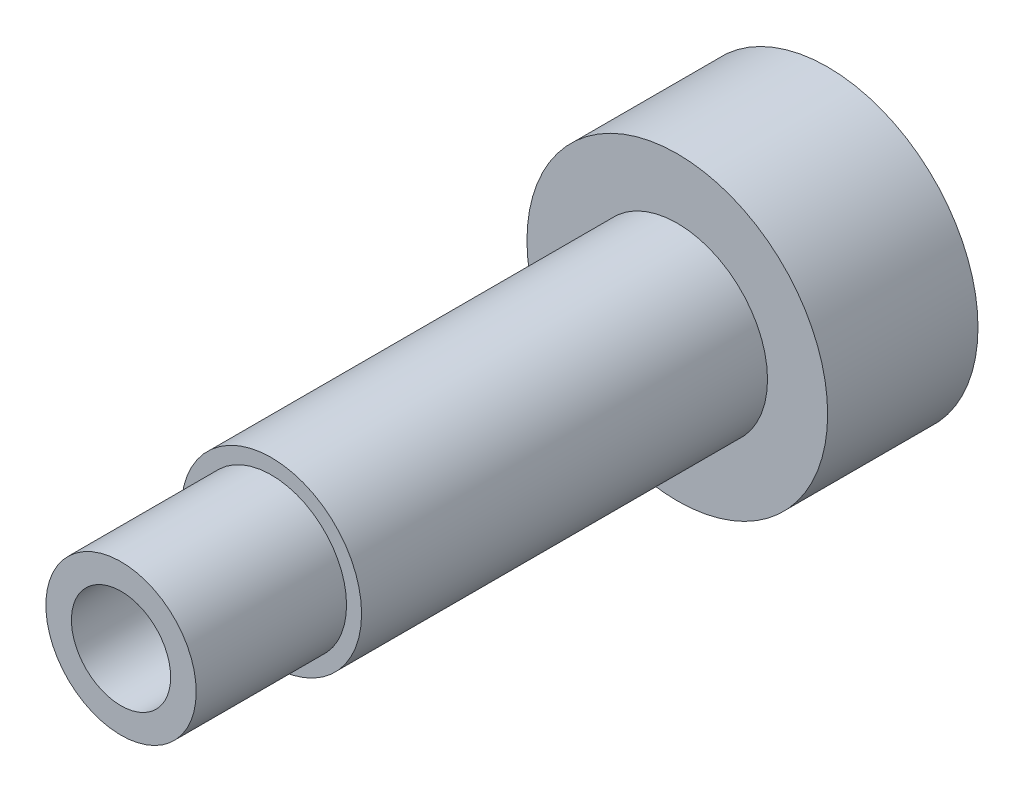
from build123d import *

# Parameters (mm, degrees)
SKETCH1_R                 = 3
EXTRUDE1_DEPTH            = 13.5
SKETCH2_R                 = 2.5
EXTRUDE2_DEPTH            = 5
SKETCH3_R                 = 5
EXTRUDE3_DEPTH            = 5
M4X0_7_TAPPED_HOLE1_D     = 3.3
M4X0_7_TAPPED_HOLE1_DEPTH = 10.1
M4X0_7_TAPPED_HOLE1_TIP   = 0.991420021


with BuildPart() as part:
    # Sketch1 → Extrude1 (new body)
    with BuildSketch(Plane.XY):
        Circle(SKETCH1_R)
    extrude(amount=EXTRUDE1_DEPTH)

    # Sketch2 → Extrude2 (add)
    with BuildSketch(Plane.XY.offset(13.5)):
        Circle(SKETCH2_R)
    extrude(amount=EXTRUDE2_DEPTH)

    # Sketch3 → Extrude3 (add)
    with BuildSketch(Plane(origin=(0, 0, 0), x_dir=(-1, 0, 0), z_dir=(0, 0, -1))):
        Circle(SKETCH3_R)
    extrude(amount=EXTRUDE3_DEPTH)

    # M4x0.7 Tapped Hole1
    with Locations(Plane.XY.offset(18.5)):
        with Locations((0, 0)):
            Hole(M4X0_7_TAPPED_HOLE1_D / 2, depth=M4X0_7_TAPPED_HOLE1_DEPTH)
            with Locations((0, 0, -(M4X0_7_TAPPED_HOLE1_DEPTH + M4X0_7_TAPPED_HOLE1_TIP / 2))):  # 118° drill point
                Cone(0, M4X0_7_TAPPED_HOLE1_D / 2, M4X0_7_TAPPED_HOLE1_TIP, mode=Mode.SUBTRACT)


solid = part.part
